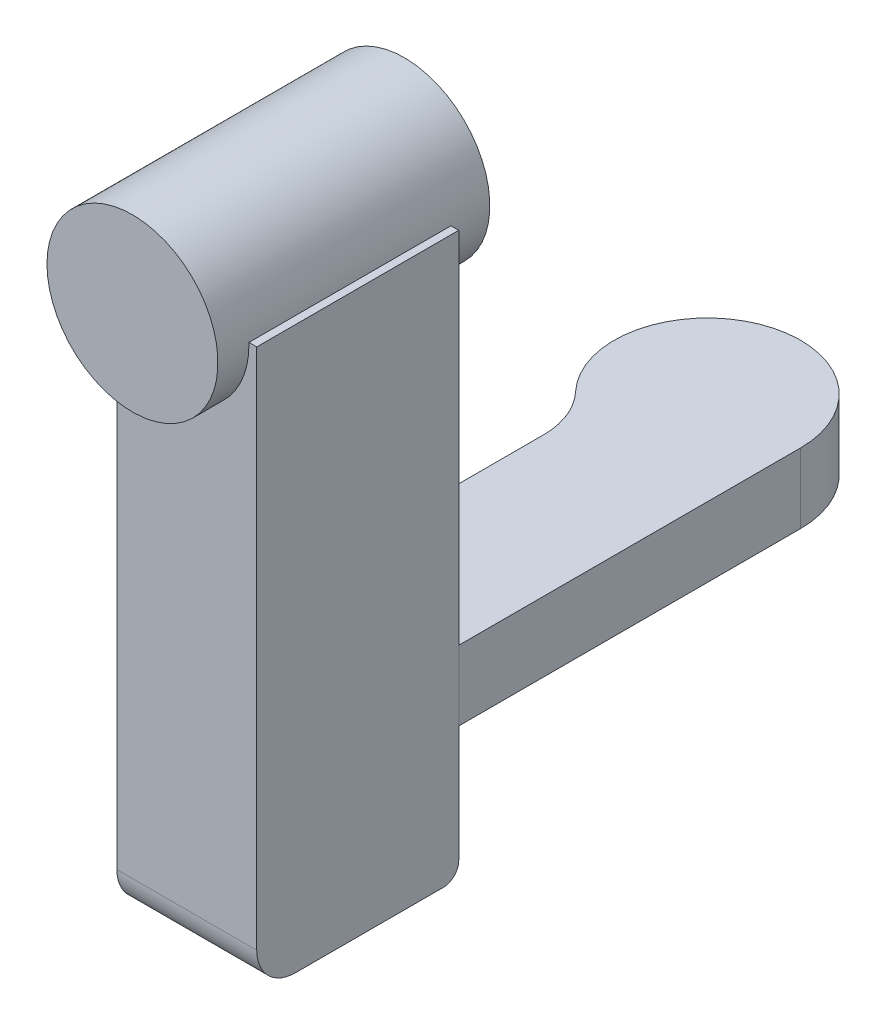
from build123d import *

# Parameters (mm, degrees)
BOSS_EXTRUDE1_DEPTH      = 9
BOSS_EXTRUDE2_DEPTH      = 46.257033012
BOSS_EXTRUDE2_DEPTH_BACK = 26
SKETCH2_W                = 18
SKETCH2_H                = 26
FILLET2_R                = 2
FILLET3_R                = 5
BOSS_EXTRUDE3_DEPTH      = 5
BOSS_EXTRUDE3_DEPTH_BACK = 30
SKETCH3_R                = 11


with BuildPart() as part:
    # Sketch1 → Boss-Extrude1 (new body)
    with BuildSketch(Plane(origin=(0, 0, 0), x_dir=(1, 0, 0), z_dir=(0, 1, 0))):
        with BuildLine():
            Line((12, 0), (12, -44))
            Line((12, -44), (-6, -44))
            Line((-6, -44), (-6, -15.099668871))
            ThreePointArc((-6, -15.099668871), (-6.706796227, -11.406924141), (-8.727272727, -8.23618302))
            ThreePointArc((-8.727272727, -8.23618302), (-4.431293675, 11.151844527), (12, 0))
        make_face()
    extrude(amount=BOSS_EXTRUDE1_DEPTH)


with BuildPart() as body_2:
    # Sketch2 → Boss-Extrude2 (new, two sides: drawn at the far end of the back side and taken through both)
    with BuildSketch(Plane(origin=(0, 9, 0), x_dir=(1, 0, 0), z_dir=(0, 1, 0)).offset(-BOSS_EXTRUDE2_DEPTH_BACK)):
        with Locations((3, -57)):
            Rectangle(SKETCH2_W, SKETCH2_H)
    extrude(amount=BOSS_EXTRUDE2_DEPTH + BOSS_EXTRUDE2_DEPTH_BACK)

    # Fillet2
    fillet2_edges = [body_2.edges().sort_by_distance(p)[0] for p in [
        (3, -17, 44),
    ]]
    fillet(fillet2_edges, radius=FILLET2_R)

    # Fillet3
    fillet3_edges = [body_2.edges().sort_by_distance(p)[0] for p in [
        (3, -17, 70),
    ]]
    fillet(fillet3_edges, radius=FILLET3_R)

    # Sketch3 → Boss-Extrude3 (add, two sides: drawn at the far end of the back side and taken through both)
    with BuildSketch(Plane(origin=(0, 0, 44), x_dir=(-1, 0, 0), z_dir=(0, 0, -1)).offset(-BOSS_EXTRUDE3_DEPTH_BACK)):
        with Locations((0, 55)):
            Circle(SKETCH3_R)
    extrude(amount=BOSS_EXTRUDE3_DEPTH + BOSS_EXTRUDE3_DEPTH_BACK)


solid = Compound([part.part, body_2.part])
